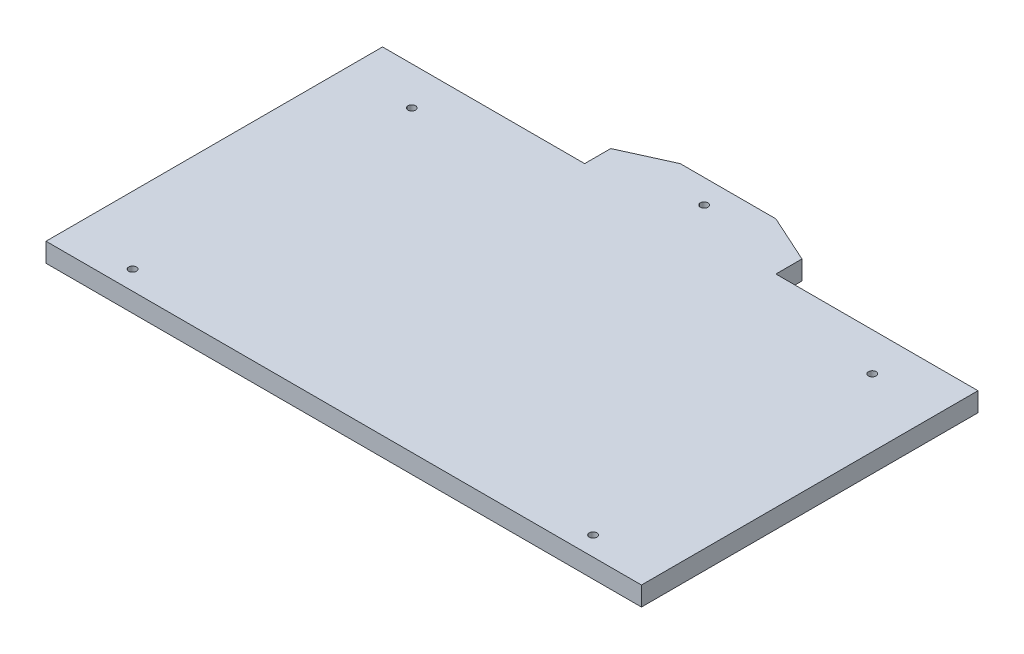
from build123d import *

# Parameters (mm, degrees)
SKETCH1_W           = 155.702807198
SKETCH1_H           = 58
SKETCH1_R           = 1.5
BOSS_EXTRUDE2_DEPTH = 5
SKETCH2_R           = 1
BOSS_EXTRUDE3_DEPTH = 5
SKETCH3_R           = 1.5
SKETCH3_R_2         = 1
BOSS_EXTRUDE4_DEPTH = 5


with BuildPart() as part:
    # Sketch1 → Boss-Extrude2 (new body)
    with BuildSketch(Plane(origin=(0, 0, 0), x_dir=(1, 0, 0), z_dir=(0, 1, 0))):
        with Locations((1.171695753, -5)):
            Rectangle(SKETCH1_W, SKETCH1_H)
        Polygon((-76.679707846, 44), (-76.679707846, 24), (79.023099352, 24), (79.023099352, 44), (62.885457038, 44), (59.885457038, 44), (-57.542065533, 44), (-60.542065533, 44), align=None)
        with Locations((-59.042065533, 34)):
            Circle(SKETCH1_R, mode=Mode.SUBTRACT)
        with Locations((61.385457038, 34)):
            Circle(SKETCH1_R, mode=Mode.SUBTRACT)
        Polygon((-76.679707846, -44), (-60.542065533, -44), (-57.542065533, -44), (59.885457038, -44), (62.885457038, -44), (79.023099352, -44), (79.023099352, -34), (-76.679707846, -34), align=None)
        with Locations((-59.042065533, -39)):
            Circle(SKETCH1_R, mode=Mode.SUBTRACT)
        with Locations((61.385457038, -39)):
            Circle(SKETCH1_R, mode=Mode.SUBTRACT)
    extrude(amount=BOSS_EXTRUDE2_DEPTH)

    # Sketch2 → Boss-Extrude3 (add)
    with BuildSketch(Plane(origin=(0, 5, 0), x_dir=(1, 0, 0), z_dir=(0, 1, 0))):
        Polygon((-23.828304247, 44), (26.171695753, 44), (26.171695753, 50.823606938), (13.671695753, 56.49492606), (-11.328304247, 56.49492606), (-23.828304247, 50.823606938), align=None)
        with Locations((1.171695753, 50.24746303)):
            Circle(SKETCH2_R, mode=Mode.SUBTRACT)
    extrude(amount=-BOSS_EXTRUDE3_DEPTH)

    # Sketch3 → Boss-Extrude4 (add)
    with BuildSketch(Plane(origin=(0, 5, 0), x_dir=(1, 0, 0), z_dir=(0, 1, 0))):
        with Locations((61.385457038, 34)):
            Circle(SKETCH3_R)
        with Locations((61.385457038, 34)):
            Circle(SKETCH3_R_2, mode=Mode.SUBTRACT)
        with Locations((61.385457038, -39)):
            Circle(SKETCH3_R)
        with Locations((61.385457038, -39)):
            Circle(SKETCH3_R_2, mode=Mode.SUBTRACT)
        with Locations((-59.042065533, -39)):
            Circle(SKETCH3_R)
        with Locations((-59.042065533, -39)):
            Circle(SKETCH3_R_2, mode=Mode.SUBTRACT)
        with Locations((-59.042065533, 34)):
            Circle(SKETCH3_R)
        with Locations((-59.042065533, 34)):
            Circle(SKETCH3_R_2, mode=Mode.SUBTRACT)
    extrude(amount=-BOSS_EXTRUDE4_DEPTH)


solid = part.part
